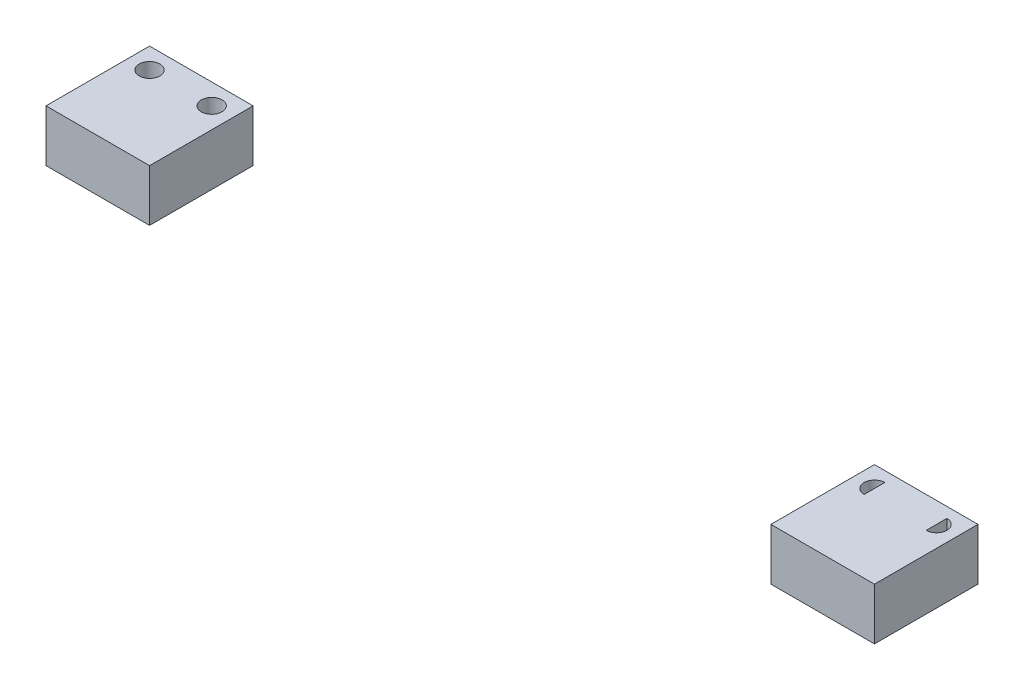
from build123d import *

# Parameters (mm, degrees)
SKETCH1_W           = 10
SKETCH1_H           = 10
BOSS_EXTRUDE1_DEPTH = 2.5
SKETCH3_R           = 1
CUT_EXTRUDE2_DEPTH  = 6
CUT_EXTRUDE3_DEPTH  = 6


with BuildPart() as part:
    # Sketch1 → Boss-Extrude1 (new body, symmetric)
    with BuildSketch(Plane(origin=(0, 0, 0), x_dir=(1, 0, 0), z_dir=(0, 1, 0))):
        with Locations((-35, 0)):
            Rectangle(SKETCH1_W, SKETCH1_H)
    extrude(amount=BOSS_EXTRUDE1_DEPTH, both=True)


with BuildPart() as body_2:
    # Mirror1: mirrored copy
    add(part.part.mirror(Plane(origin=(0, 0, 0), x_dir=(0, 0, 1), z_dir=(1, 0, 0))))

    # Sketch4 → Cut-Extrude3 (cut, through all)
    with BuildSketch(Plane(origin=(0, 2.5, 0), x_dir=(1, 0, 0), z_dir=(0, 1, 0))):
        with BuildLine():
            Line((32, 4), (32, 2))
            ThreePointArc((32, 2), (31, 3), (32, 4))
        make_face()
    cut_extrude3 = extrude(amount=-CUT_EXTRUDE3_DEPTH, mode=Mode.SUBTRACT)

    # Mirror4: Cut-Extrude3 across plane
    add(cut_extrude3.mirror(Plane.ZY.offset(-35)), mode=Mode.SUBTRACT)


with BuildPart() as part_1:
    add(part.part)

    # Sketch3 → Cut-Extrude2 (cut, through all)
    with BuildSketch(Plane(origin=(0, 2.5, 0), x_dir=(1, 0, 0), z_dir=(0, 1, 0))):
        with Locations(Location((-38, 3, 0), (0, 0, 270))):  # turned: the seam where the file's is
            Circle(SKETCH3_R)
    cut_extrude2 = extrude(amount=-CUT_EXTRUDE2_DEPTH, mode=Mode.SUBTRACT)

    # Mirror3: Cut-Extrude2 across plane
    add(cut_extrude2.mirror(Plane.ZY.offset(35)), mode=Mode.SUBTRACT)


solid = Compound([body_2.part, part_1.part])
